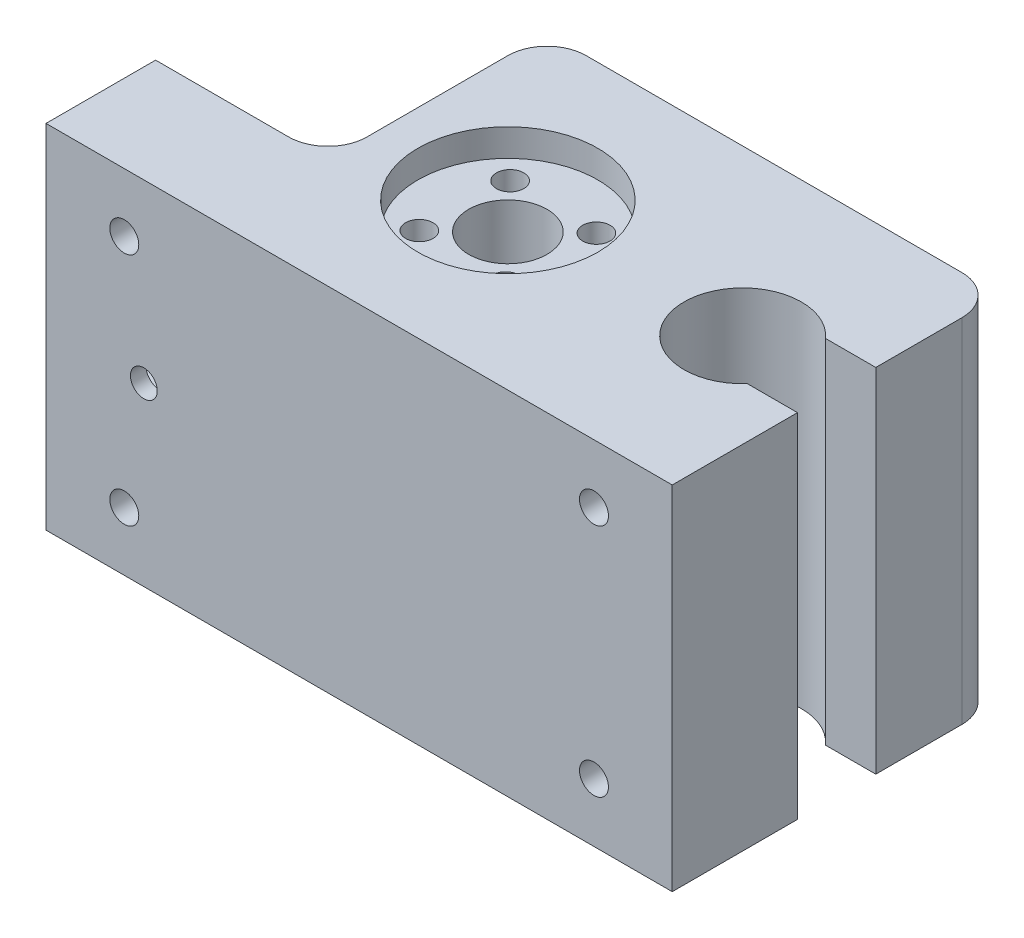
from build123d import *

# Parameters (mm, degrees)
SKETCH1_W           = 80
SKETCH1_H           = 45
BOSS_EXTRUDE1_DEPTH = 42
SKETCH3_W           = 22
SKETCH3_H           = 28
CUT_EXTRUDE2_DEPTH  = 46
SKETCH4_W           = 10
SKETCH4_H           = 17
CUT_EXTRUDE3_DEPTH  = 28
SKETCH7_R           = 11.5
CUT_EXTRUDE5_DEPTH  = 3.5
SKETCH11_R          = 1.75
CUT_EXTRUDE6_DEPTH  = 10
SKETCH12_R          = 5
CUT_EXTRUDE7_DEPTH  = 42.5
SKETCH13_R          = 7.5
CUT_EXTRUDE8_DEPTH  = 46
SKETCH14_W          = 12.099538741
SKETCH14_H          = 10
CUT_EXTRUDE9_DEPTH  = 46
SKETCH15_R          = 1.712332533
CUT_EXTRUDE10_DEPTH = 43
SKETCH16_R          = 1.85
CUT_EXTRUDE11_DEPTH = 8
FILLET2_R           = 5


with BuildPart() as part:
    # Sketch1 → Boss-Extrude1 (new body)
    with BuildSketch(Plane.XY):
        with Locations((40, 22.5)):
            Rectangle(SKETCH1_W, SKETCH1_H)
    extrude(amount=BOSS_EXTRUDE1_DEPTH)

    # Sketch3 → Cut-Extrude2 (cut, through all)
    with BuildSketch(Plane(origin=(0, 45, 0), x_dir=(1, 0, 0), z_dir=(0, 1, 0))):
        with Locations((11, -14)):
            Rectangle(SKETCH3_W, SKETCH3_H)
    extrude(amount=-CUT_EXTRUDE2_DEPTH, mode=Mode.SUBTRACT)

    # Sketch4 → Cut-Extrude3 (cut)
    with BuildSketch(Plane.ZY):
        with Locations((35, 22.5)):
            Rectangle(SKETCH4_W, SKETCH4_H)
    extrude(amount=-CUT_EXTRUDE3_DEPTH, mode=Mode.SUBTRACT)

    # Sketch7 → Cut-Extrude5 (cut)
    with BuildSketch(Plane(origin=(0, 45, 0), x_dir=(1, 0, 0), z_dir=(0, 1, 0))):
        with Locations((38, -21)):
            Circle(SKETCH7_R)
    extrude(amount=-CUT_EXTRUDE5_DEPTH, mode=Mode.SUBTRACT)

    # Sketch11 → Cut-Extrude6 (cut)
    with BuildSketch(Plane(origin=(0, 41.5, 0), x_dir=(1, 0, 0), z_dir=(0, 1, 0))):
        with Locations((32.201639679, -26.511716392)):
            Circle(SKETCH11_R)
        with Locations((32.488283608, -15.201639679)):
            Circle(SKETCH11_R)
        with Locations((43.798360321, -15.488283608)):
            Circle(SKETCH11_R)
        with Locations((43.511716392, -26.798360321)):
            Circle(SKETCH11_R)
    extrude(amount=-CUT_EXTRUDE6_DEPTH, mode=Mode.SUBTRACT)

    # Sketch12 → Cut-Extrude7 (cut, through all)
    with BuildSketch(Plane(origin=(0, 41.5, 0), x_dir=(1, 0, 0), z_dir=(0, 1, 0))):
        with Locations((38, -21)):
            Circle(SKETCH12_R)
    extrude(amount=-CUT_EXTRUDE7_DEPTH, mode=Mode.SUBTRACT)

    # Sketch13 → Cut-Extrude8 (cut, through all)
    with BuildSketch(Plane(origin=(0, 45, 0), x_dir=(1, 0, 0), z_dir=(0, 1, 0))):
        with Locations((68, -21)):
            Circle(SKETCH13_R)
    extrude(amount=-CUT_EXTRUDE8_DEPTH, mode=Mode.SUBTRACT)

    # Sketch14 → Cut-Extrude9 (cut, through all)
    with BuildSketch(Plane(origin=(0, 45, 0), x_dir=(1, 0, 0), z_dir=(0, 1, 0))):
        with Locations((73.950230629, -21)):
            Rectangle(SKETCH14_W, SKETCH14_H)
    extrude(amount=-CUT_EXTRUDE9_DEPTH, mode=Mode.SUBTRACT)

    # Sketch15 → Cut-Extrude10 (cut, through all)
    with BuildSketch(Plane.XY.offset(42)):
        with Locations((12.5, 22.500000001)):
            Circle(SKETCH15_R)
    extrude(amount=-CUT_EXTRUDE10_DEPTH, mode=Mode.SUBTRACT)

    # Sketch16 → Cut-Extrude11 (cut)
    with BuildSketch(Plane.XY.offset(42)):
        with Locations((10, 37.5)):
            Circle(SKETCH16_R)
        with Locations((70, 37.5)):
            Circle(SKETCH16_R)
        with Locations((70, 7.5)):
            Circle(SKETCH16_R)
        with Locations((10, 7.5)):
            Circle(SKETCH16_R)
    extrude(amount=-CUT_EXTRUDE11_DEPTH, mode=Mode.SUBTRACT)

    # Fillet2
    fillet2_edges = [part.edges().sort_by_distance(p)[0] for p in [
        (22, 22.5, 0),
        (22, 22.5, 28),
        (80, 22.5, 0),
    ]]
    fillet(fillet2_edges, radius=FILLET2_R)


solid = part.part
